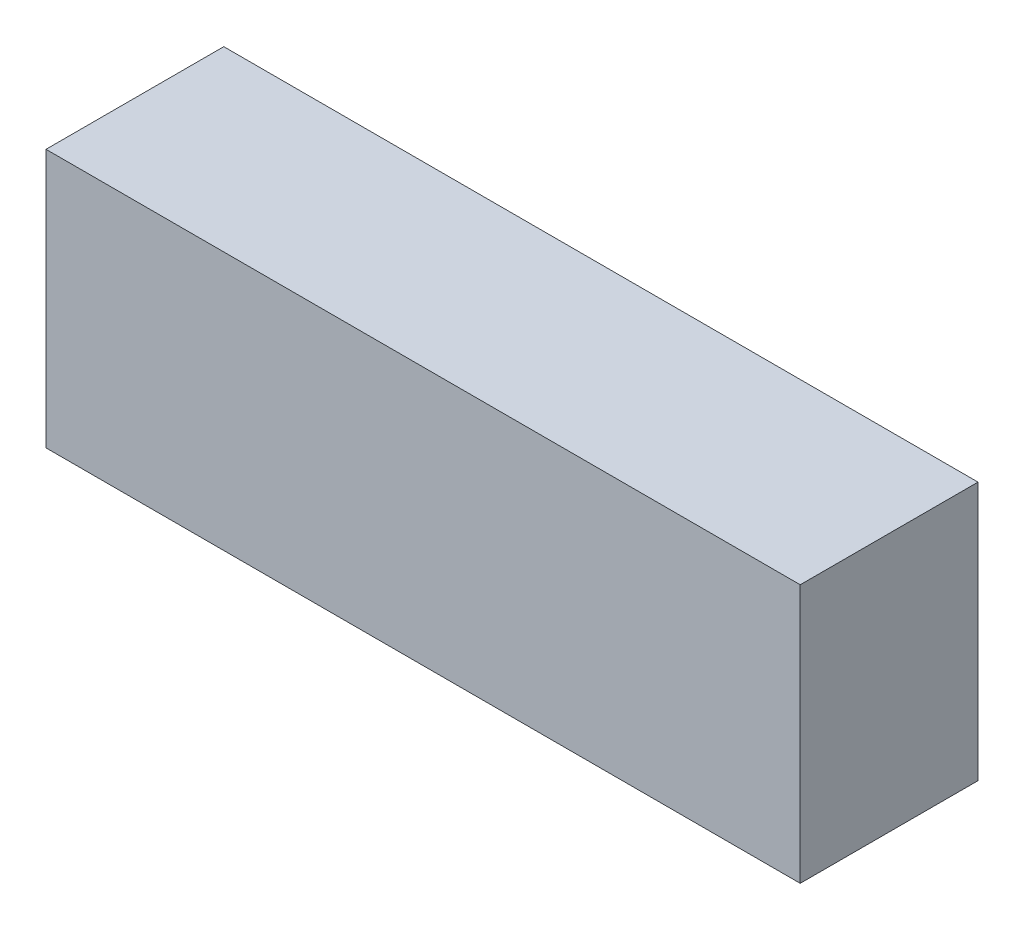
from build123d import *

# Parameters (mm, degrees)
SKETCH1_W           = 88.9
SKETCH1_H           = 30.48
BOSS_EXTRUDE1_DEPTH = 20.955


with BuildPart() as part:
    # Sketch1 → Boss-Extrude1 (new body)
    with BuildSketch(Plane.XY):
        Rectangle(SKETCH1_W, SKETCH1_H)
    extrude(amount=BOSS_EXTRUDE1_DEPTH)


solid = part.part
